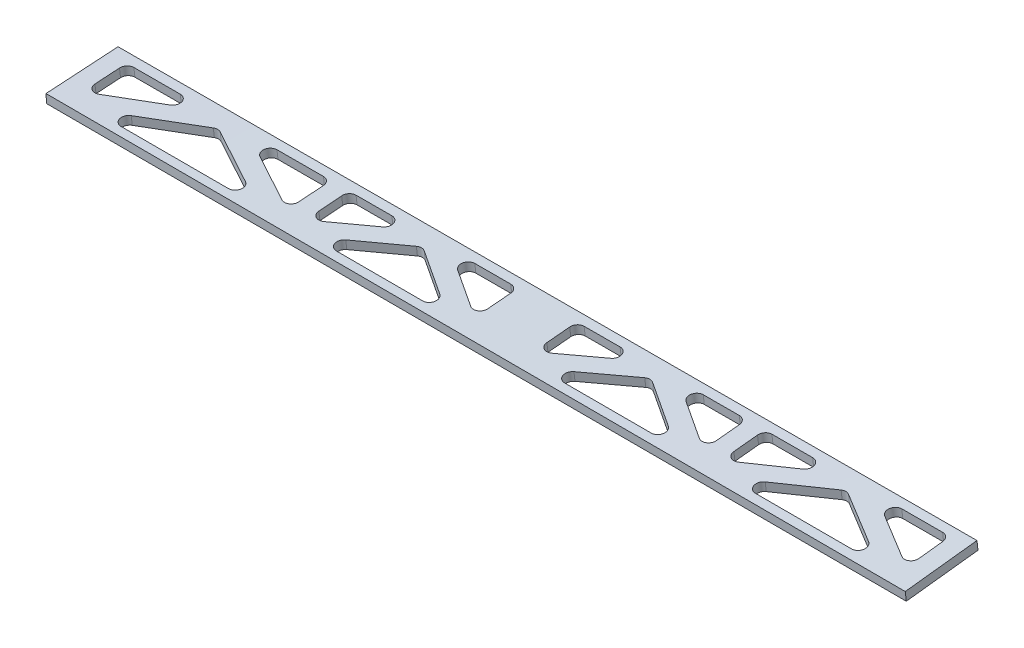
from build123d import *

# Parameters (mm, degrees)
CUT_EXTRUDE1_DEPTH      = 7.548983644
CUT_EXTRUDE1_DEPTH_BACK = 4.364562639
FILLET1_R               = 2.54


with BuildPart() as part:
    # Sketch1_7 → Loft6 section 0
    with BuildSketch(Plane(origin=(0, 0, 0), x_dir=(0, 0, -1), z_dir=(1, 0, 0))):
        Polygon((17.276227552, -57.065250581), (16.90927633, -53.911527099), (42.139064186, -50.975917325), (42.506015408, -54.129640807), align=None)
    # Sketch2_7 → Loft6 section 1
    with BuildSketch(Plane(origin=(-301.244, 0, 0), x_dir=(0, 0, -1), z_dir=(1, 0, 0))):
        Polygon((41.356959606, -53.811683647), (16.006708373, -55.400633756), (15.80808961, -52.231852352), (41.158340842, -50.642902243), align=None)
    loft()

    # Sketch3 → Cut-Extrude1 (cut, two sides)
    with BuildSketch(Plane(origin=(-0.087388543, -58.286187953, -6.781884336), x_dir=(0.999998891, -0.001479272, -0.000172121), z_dir=(0.001489252, 0.993297633, 0.11557506))) as cut_extrude1_sk:
        Polygon((-6.26261136, 32.766822272), (-6.26261136, 17.393228479), (-32.455584293, 32.670777444), align=None)
        Polygon((-131.099204967, 13.274784351), (-83.40258785, 13.443980496), (-107.250896408, 28.62662449), align=None)
        Polygon((-157.645271585, 32.211729825), (-181.421702548, 32.124546014), (-157.645271585, 16.94733015), align=None)
        Polygon((-211.045266858, 12.991188441), (-163.513545553, 13.159799645), (-187.279406206, 28.33026816), align=None)
        Polygon((-288.036648197, 12.71807379), (-230.034443055, 12.923827366), (-259.034933805, 28.243885147), align=None)
        Polygon((-223.282497269, 31.971050158), (-252.294417132, 31.86466877), (-223.282497269, 16.538573343), align=None)
        Polygon((-294.807195513, 31.708782209), (-294.808418661, 16.295541654), (-265.81842445, 31.815078715), align=None)
        Polygon((-216.932497269, 31.994334443), (-216.932497269, 16.749185885), (-193.177210862, 32.081440721), align=None)
        Polygon((-71.173287013, 32.528806731), (-71.173287013, 17.174368617), (-45.002296159, 32.624770953), align=None)
        Polygon((-77.523287013, 32.505522445), (-77.523287013, 17.228655051), (-101.382178139, 32.418036268), align=None)
        Polygon((-136.997476861, 32.287441501), (-136.997476861, 17.029824761), (-113.159754822, 32.374850055), align=None)
        Polygon((-64.890219535, 13.509650172), (-12.526251273, 13.695403001), (-38.708235404, 28.96654254), align=None)
    extrude(amount=CUT_EXTRUDE1_DEPTH, mode=Mode.SUBTRACT)
    extrude(cut_extrude1_sk.sketch, amount=-CUT_EXTRUDE1_DEPTH_BACK, mode=Mode.SUBTRACT)

    # Fillet1
    fillet1_edges = [part.edges().sort_by_distance(p)[0] for p in [
        (-230.117865805, -53.977277278, -19.291539059),
        (-223.366178328, -53.736783334, -22.902689179),
        (-163.59743207, -54.308528458, -19.567646022),
        (-157.729355388, -54.00670927, -23.345610863),
        (-83.487032059, -54.706905089, -19.90009717),
        (-77.607848982, -54.352382748, -23.669054523),
        (-6.347597868, -54.66922668, -23.871604589),
        (-12.611188138, -55.058860637, -20.194167648),
        (-64.97479249, -54.798878428, -19.976911434),
        (-71.257885412, -54.38765165, -23.618505557),
        (-137.081684318, -54.094921847, -23.438925988),
        (-131.183317244, -54.469790979, -19.702170155),
        (-211.128822059, -54.071879002, -19.370361959),
        (-288.119666063, -53.68810876, -19.050751193),
        (-217.016227357, -53.749839871, -23.116241805),
        (-294.891668992, -53.424682672, -22.621703437),
        (-38.793147177, -53.25779432, -35.35877064),
        (-107.335605983, -53.111522292, -34.999539872),
        (-187.363879631, -52.929075547, -34.679955606),
        (-259.119206729, -52.752256197, -34.572416012),
        (-294.891643164, -52.441880363, -38.024575164),
        (-252.378948773, -52.511326935, -38.189593859),
        (-217.017098556, -52.568949038, -38.326838934),
        (-181.50637358, -52.626682916, -38.464646594),
        (-137.082234868, -52.69872388, -38.637023371),
        (-101.467005652, -52.756331754, -38.775202152),
        (-71.258173326, -52.805091554, -38.892393367),
        (-32.540545761, -52.867446898, -39.042577234),
        (-6.347623539, -52.90954286, -39.144168097),
        (-45.087233299, -52.847257289, -38.993911201),
        (-77.608160978, -52.794849957, -38.867760335),
        (-113.244559371, -52.737296054, -38.729509687),
        (-157.729989206, -52.665265686, -38.556907883),
        (-193.261858827, -52.60758518, -38.419028377),
        (-223.367086064, -52.558611317, -38.302194717),
        (-265.902929403, -52.489255242, -38.137101097),
    ]]
    fillet(fillet1_edges, radius=FILLET1_R)


solid = part.part
